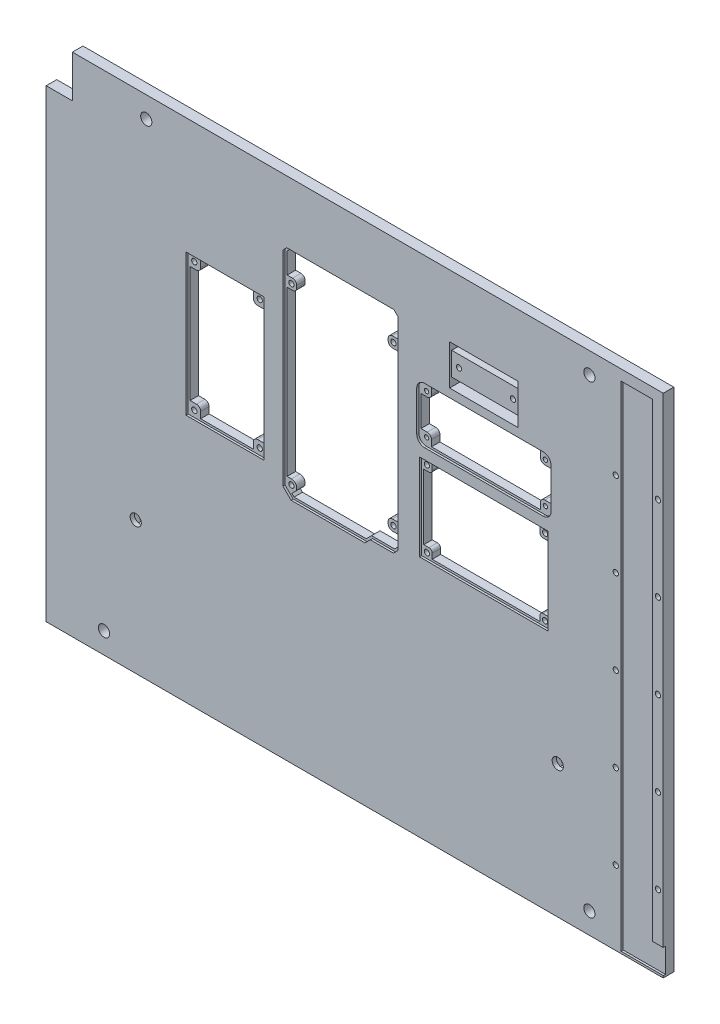
from build123d import *

# Parameters (mm, degrees)
SKETCH1_W            = 300
SKETCH1_H            = 220
BOSS_EXTRUDE1_DEPTH  = 5
SKETCH5_W            = 280
SKETCH5_H            = 5
BOSS_EXTRUDE3_DEPTH  = 20
SKETCH7_W            = 37
SKETCH7_H            = 67
SKETCH7_W_2          = 61
SKETCH7_H_2          = 41
SKETCH7_W_3          = 32.5
SKETCH7_H_3          = 19
CUT_EXTRUDE3_DEPTH   = 1
SKETCH9_R            = 1.25
SKETCH9_R_2          = 1.025
SKETCH9_W            = 32.5
SKETCH9_H            = 4
SKETCH9_W_2          = 32
CUT_EXTRUDE4_DEPTH   = 5
SKETCH10_R           = 2.65
CUT_EXTRUDE5_DEPTH   = 10
CUT_EXTRUDE6_DEPTH   = 3
SKETCH12_W           = 15.175839796
SKETCH12_H           = 464.77021423
FORPRINTADJUST_DEPTH = 5


with BuildPart() as part:
    # Sketch1 → Boss-Extrude1 (new body)
    with BuildSketch(Plane.XY):
        with Locations((150, 110)):
            Rectangle(SKETCH1_W, SKETCH1_H)
    extrude(amount=BOSS_EXTRUDE1_DEPTH)

    # Sketch5 → Boss-Extrude3 (add)
    with BuildSketch(Plane(origin=(0, 220, 0), x_dir=(1, 0, 0), z_dir=(0, 1, 0))):
        with Locations((160, -2.5)):
            Rectangle(SKETCH5_W, SKETCH5_H)
    extrude(amount=BOSS_EXTRUDE3_DEPTH)

    # Sketch7 → Cut-Extrude3 (cut)
    with BuildSketch(Plane.XY.offset(5)):
        Polygon((295, 12.5), (300, 12.5), (300, 1), (280, 1), (280, 235), (295, 235), align=None)
        Polygon((119.7688, 111.748893219), (123.617693219, 107.9), (158.652106781, 107.9), (161.192106781, 110.44), (172.128671481, 110.44), (174.185, 112.496328519), (174.185, 208.683106781), (172.368106781, 210.5), (121.585693219, 210.5), (119.7688, 208.683106781), align=None)
        with Locations((92.2688, 151.4)):
            Rectangle(SKETCH7_W, SKETCH7_H)
        with BuildLine():
            Line((243.145, 187.5), (186.855, 187.5))
            ThreePointArc((186.855, 187.5), (184.259918113, 186.425081887), (183.185, 183.83))
            Line((183.185, 183.83), (183.185, 164.77))
            ThreePointArc((183.185, 164.77), (184.259918113, 162.174918113), (186.855, 161.1))
            Line((186.855, 161.1), (243.145, 161.1))
            ThreePointArc((243.145, 161.1), (245.740081887, 162.174918113), (246.815, 164.77))
            Line((246.815, 164.77), (246.815, 183.83))
            ThreePointArc((246.815, 183.83), (245.740081887, 186.425081887), (243.145, 187.5))
        make_face()
        with Locations((215, 135.6)):
            Rectangle(SKETCH7_W_2, SKETCH7_H_2)
        with Locations((215, 201)):
            Rectangle(SKETCH7_W_3, SKETCH7_H_3)
    extrude(amount=-CUT_EXTRUDE3_DEPTH, mode=Mode.SUBTRACT)

    # Sketch9 → Cut-Extrude4 (cut)
    with BuildSketch(Plane.XY.offset(5)):
        with Locations((76.7688, 181.9)):
            Circle(SKETCH9_R)
        with Locations((107.7688, 181.9)):
            Circle(SKETCH9_R)
        with Locations((107.7688, 120.9)):
            Circle(SKETCH9_R)
        with Locations((76.7688, 120.9)):
            Circle(SKETCH9_R)
        with Locations((297.5, 35.1)):
            Circle(SKETCH9_R)
        with Locations((277.5, 35.1)):
            Circle(SKETCH9_R)
        with Locations((277.5, 75.1)):
            Circle(SKETCH9_R)
        with Locations((297.5, 75.1)):
            Circle(SKETCH9_R)
        with Locations((297.5, 115.1)):
            Circle(SKETCH9_R)
        with Locations((277.5, 115.1)):
            Circle(SKETCH9_R)
        with Locations((277.5, 155.1)):
            Circle(SKETCH9_R)
        with Locations((297.5, 155.1)):
            Circle(SKETCH9_R)
        with Locations((297.5, 195.1)):
            Circle(SKETCH9_R)
        with Locations((277.5, 195.1)):
            Circle(SKETCH9_R)
        with Locations((122.8088, 113.2514)):
            Circle(SKETCH9_R)
        with Locations((171.145, 120.7444)):
            Circle(SKETCH9_R)
        with Locations((122.8088, 195.8776)):
            Circle(SKETCH9_R)
        with Locations((171.145, 195.8776)):
            Circle(SKETCH9_R)
        with Locations((202.2, 201)):
            Circle(SKETCH9_R)
        with Locations((227.8, 201)):
            Circle(SKETCH9_R)
        with Locations((186.865, 183.82)):
            Circle(SKETCH9_R_2)
        with Locations((186.865, 164.78)):
            Circle(SKETCH9_R_2)
        with Locations((243.145, 164.77)):
            Circle(SKETCH9_R_2)
        with Locations((243.135, 183.82)):
            Circle(SKETCH9_R_2)
        with Locations((187, 153.6)):
            Circle(SKETCH9_R)
        with Locations((243, 153.6)):
            Circle(SKETCH9_R)
        with Locations((243, 117.6)):
            Circle(SKETCH9_R)
        with Locations((187, 117.6)):
            Circle(SKETCH9_R)
        with BuildLine():
            Line((79.7688, 183.9), (92.2688, 183.9))
            Line((92.2688, 183.9), (104.7688, 183.9))
            Line((104.7688, 183.9), (104.7688, 180.9))
            ThreePointArc((104.7688, 180.9), (105.354586438, 179.485786438), (106.7688, 178.9))
            Line((106.7688, 178.9), (109.7688, 178.9))
            Line((109.7688, 178.9), (109.7688, 123.9))
            Line((109.7688, 123.9), (106.7688, 123.9))
            ThreePointArc((106.7688, 123.9), (105.354586438, 123.314213562), (104.7688, 121.9))
            Line((104.7688, 121.9), (104.7688, 118.9))
            Line((104.7688, 118.9), (92.2688, 118.9))
            Line((92.2688, 118.9), (79.7688, 118.9))
            Line((79.7688, 118.9), (79.7688, 121.9))
            ThreePointArc((79.7688, 121.9), (79.183013562, 123.314213562), (77.7688, 123.9))
            Line((77.7688, 123.9), (74.7688, 123.9))
            Line((74.7688, 123.9), (74.7688, 178.9))
            Line((74.7688, 178.9), (77.7688, 178.9))
            ThreePointArc((77.7688, 178.9), (79.183013562, 179.485786438), (79.7688, 180.9))
            Line((79.7688, 180.9), (79.7688, 183.9))
        make_face()
        with BuildLine():
            Line((185.5, 120.1), (185.5, 151.1))
            Line((185.5, 151.1), (187.966791834, 151.1))
            ThreePointArc((187.966791834, 151.1), (189.050933725, 151.549066275), (189.5, 152.633208166))
            Line((189.5, 152.633208166), (189.5, 155.1))
            Line((189.5, 155.1), (240.5, 155.1))
            Line((240.5, 155.1), (240.5, 152.633208166))
            ThreePointArc((240.5, 152.633208166), (240.949066275, 151.549066275), (242.033208166, 151.1))
            Line((242.033208166, 151.1), (244.5, 151.1))
            Line((244.5, 151.1), (244.5, 120.1))
            Line((244.5, 120.1), (242.033208166, 120.1))
            ThreePointArc((242.033208166, 120.1), (240.949066275, 119.650933725), (240.5, 118.566791834))
            Line((240.5, 118.566791834), (240.5, 116.1))
            Line((240.5, 116.1), (189.5, 116.1))
            Line((189.5, 116.1), (189.5, 118.566791834))
            ThreePointArc((189.5, 118.566791834), (189.050933725, 119.650933725), (187.966791834, 120.1))
            Line((187.966791834, 120.1), (185.5, 120.1))
        make_face()
        with BuildLine():
            Line((173.185, 208.268893219), (173.185, 198.3776))
            Line((173.185, 198.3776), (170.645, 198.3776))
            ThreePointArc((170.645, 198.3776), (169.230786438, 197.791813562), (168.645, 196.3776))
            Line((168.645, 196.3776), (168.645, 195.3776))
            ThreePointArc((168.645, 195.3776), (169.230786438, 193.963386438), (170.645, 193.3776))
            Line((170.645, 193.3776), (173.185, 193.3776))
            Line((173.185, 193.3776), (173.185, 123.2444))
            Line((173.185, 123.2444), (170.645, 123.2444))
            ThreePointArc((170.645, 123.2444), (169.230786438, 122.658613562), (168.645, 121.2444))
            Line((168.645, 121.2444), (168.645, 120.2444))
            ThreePointArc((168.645, 120.2444), (169.230786438, 118.830186438), (170.645, 118.2444))
            Line((170.645, 118.2444), (173.185, 118.2444))
            Line((173.185, 118.2444), (173.185, 112.910542081))
            Line((173.185, 112.910542081), (171.714457919, 111.44))
            Line((171.714457919, 111.44), (160.777893219, 111.44))
            Line((160.777893219, 111.44), (158.237893219, 108.9))
            Line((158.237893219, 108.9), (124.031906781, 108.9))
            Line((124.031906781, 108.9), (123.012420344, 109.919486438))
            Line((123.012420344, 109.919486438), (124.576566953, 111.483633047))
            ThreePointArc((124.576566953, 111.483633047), (125.118498831, 114.208108581), (122.8088, 115.7514))
            Line((122.8088, 115.7514), (120.7688, 115.7514))
            Line((120.7688, 115.7514), (120.7688, 193.3776))
            Line((120.7688, 193.3776), (123.3088, 193.3776))
            ThreePointArc((123.3088, 193.3776), (124.723013562, 193.963386438), (125.3088, 195.3776))
            Line((125.3088, 195.3776), (125.3088, 196.3776))
            ThreePointArc((125.3088, 196.3776), (124.723013562, 197.791813562), (123.3088, 198.3776))
            Line((123.3088, 198.3776), (120.7688, 198.3776))
            Line((120.7688, 198.3776), (120.7688, 208.268893219))
            Line((120.7688, 208.268893219), (121.999906781, 209.5))
            Line((121.999906781, 209.5), (171.953893219, 209.5))
            Line((171.953893219, 209.5), (173.185, 208.268893219))
        make_face()
        with Locations((215, 208.5)):
            Rectangle(SKETCH9_W, SKETCH9_H)
        with Locations((214.75, 193.5)):
            Rectangle(SKETCH9_W_2, SKETCH9_H)
        with BuildLine():
            Line((184.185, 167.1), (184.185, 181.5))
            Line((184.185, 181.5), (187.185, 181.5))
            ThreePointArc((187.185, 181.5), (188.599213562, 182.085786438), (189.185, 183.5))
            Line((189.185, 183.5), (189.185, 186.5))
            Line((189.185, 186.5), (240.815, 186.5))
            Line((240.815, 186.5), (240.815, 183.5))
            ThreePointArc((240.815, 183.5), (241.400786438, 182.085786438), (242.815, 181.5))
            Line((242.815, 181.5), (245.815, 181.5))
            Line((245.815, 181.5), (245.815, 167.1))
            Line((245.815, 167.1), (242.815, 167.1))
            ThreePointArc((242.815, 167.1), (241.400786438, 166.514213562), (240.815, 165.1))
            Line((240.815, 165.1), (240.815, 162.1))
            Line((240.815, 162.1), (189.185, 162.1))
            Line((189.185, 162.1), (189.185, 165.1))
            ThreePointArc((189.185, 165.1), (188.599213562, 166.514213562), (187.185, 167.1))
            Line((187.185, 167.1), (184.185, 167.1))
        make_face()
    extrude(amount=-CUT_EXTRUDE4_DEPTH, mode=Mode.SUBTRACT)

    # Sketch10 → Cut-Extrude5 (cut)
    with BuildSketch(Plane.XY.offset(5)):
        with Locations((50, 63)):
            Circle(SKETCH10_R)
        with Locations((250, 63)):
            Circle(SKETCH10_R)
        with Locations((35, 10)):
            Circle(SKETCH10_R)
        with Locations((265, 10)):
            Circle(SKETCH10_R)
        with Locations((265, 230)):
            Circle(SKETCH10_R)
        with Locations((55, 230)):
            Circle(SKETCH10_R)
    extrude(amount=-CUT_EXTRUDE5_DEPTH, mode=Mode.SUBTRACT)

    # Sketch11 → Cut-Extrude6 (cut)
    with BuildSketch(Plane(origin=(0, 0, 0), x_dir=(-1, 0, 0), z_dir=(0, 0, -1))):
        Polygon((-247.517393842, 67.3), (-252.482606158, 67.3), (-254.965212315, 63), (-252.482606158, 58.7), (-247.517393842, 58.7), (-245.034787685, 63), align=None)
        Polygon((-47.517393842, 67.3), (-52.482606158, 67.3), (-54.965212315, 63), (-52.482606158, 58.7), (-47.517393842, 58.7), (-45.034787685, 63), align=None)
    extrude(amount=-CUT_EXTRUDE6_DEPTH, mode=Mode.SUBTRACT)

    # Sketch12 → ForPrintAdjust (cut)
    with BuildSketch(Plane.XY.offset(5)):
        with Locations((0, 220)):
            Rectangle(SKETCH12_W, SKETCH12_H)
    extrude(amount=-FORPRINTADJUST_DEPTH, mode=Mode.SUBTRACT)


solid = part.part
